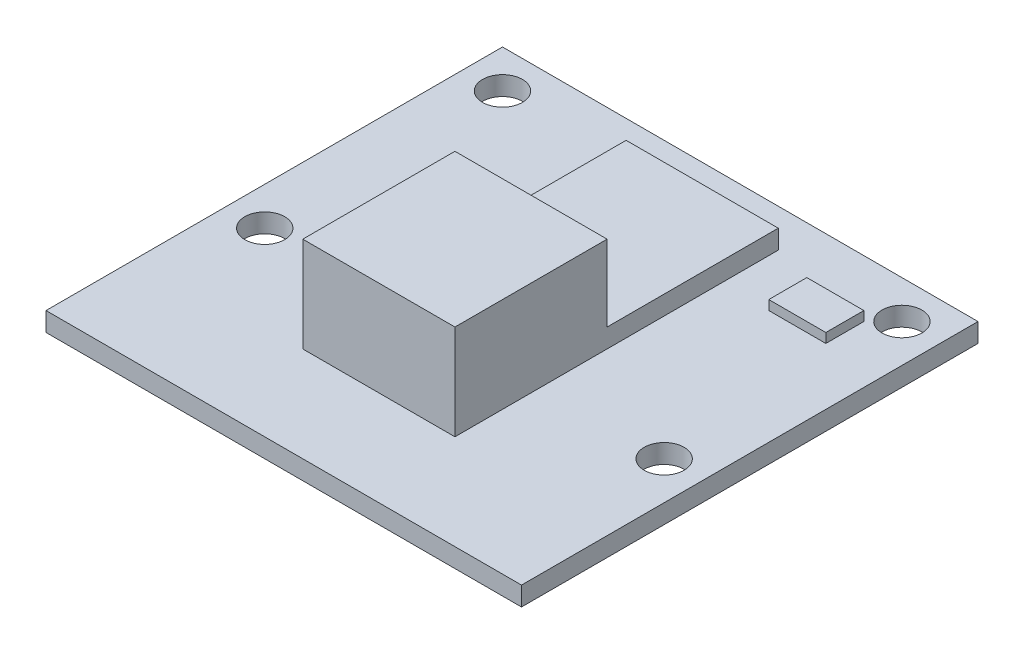
from build123d import *

# Parameters (mm, degrees)
SKETCH1_W           = 25
SKETCH1_H           = 24
BOSS_EXTRUDE1_DEPTH = 1
SKETCH2_W           = 8
SKETCH2_H           = 8
BOSS_EXTRUDE2_DEPTH = 5
SKETCH3_W           = 8
SKETCH3_H           = 9
BOSS_EXTRUDE3_DEPTH = 1
SKETCH4_W           = 3
SKETCH4_H           = 2
BOSS_EXTRUDE4_DEPTH = 0.5
CUT_EXTRUDE1_REACH  = 3
SKETCH5_R           = 1.048419625


with BuildPart() as part:
    # Sketch1 → Boss-Extrude1 (new body)
    with BuildSketch(Plane(origin=(0, 0, 0), x_dir=(1, 0, 0), z_dir=(0, 1, 0))):
        Rectangle(SKETCH1_W, SKETCH1_H)
    extrude(amount=BOSS_EXTRUDE1_DEPTH)

    # Sketch2 → Boss-Extrude2 (add)
    with BuildSketch(Plane(origin=(0, 1, 0), x_dir=(1, 0, 0), z_dir=(0, 1, 0))):
        with Locations((0, -3)):
            Rectangle(SKETCH2_W, SKETCH2_H)
    extrude(amount=BOSS_EXTRUDE2_DEPTH)

    # Sketch3 → Boss-Extrude3 (add)
    with BuildSketch(Plane(origin=(0, 1, 0), x_dir=(1, 0, 0), z_dir=(0, 1, 0))):
        with Locations((0, 5.5)):
            Rectangle(SKETCH3_W, SKETCH3_H)
    extrude(amount=BOSS_EXTRUDE3_DEPTH)

    # Sketch4 → Boss-Extrude4 (add)
    with BuildSketch(Plane(origin=(0, 1, 0), x_dir=(1, 0, 0), z_dir=(0, 1, 0))):
        with Locations((8, 8)):
            Rectangle(SKETCH4_W, SKETCH4_H)
    extrude(amount=BOSS_EXTRUDE4_DEPTH)

    # Sketch5 → Cut-Extrude1 (cut, up to next)
    with BuildSketch(Plane(origin=(0, 1, 0), x_dir=(1, 0, 0), z_dir=(0, 1, 0)), mode=Mode.PRIVATE) as cut_extrude1_sk1:
        with Locations((-10.5, 10)):
            Circle(SKETCH5_R)
    cut_extrude1_tool1 = extrude(cut_extrude1_sk1.sketch, amount=-CUT_EXTRUDE1_REACH, mode=Mode.PRIVATE) & part.part
    add(cut_extrude1_tool1.solids().sort_by_distance((-10.5, 1, -10))[0], mode=Mode.SUBTRACT)
    # Sketch5 → Cut-Extrude1 (cut, up to next)
    with BuildSketch(Plane(origin=(0, 1, 0), x_dir=(1, 0, 0), z_dir=(0, 1, 0)), mode=Mode.PRIVATE) as cut_extrude1_sk2:
        with Locations((10.5, 10)):
            Circle(SKETCH5_R)
    cut_extrude1_tool2 = extrude(cut_extrude1_sk2.sketch, amount=-CUT_EXTRUDE1_REACH, mode=Mode.PRIVATE) & part.part
    add(cut_extrude1_tool2.solids().sort_by_distance((10.5, 1, -10))[0], mode=Mode.SUBTRACT)
    # Sketch5 → Cut-Extrude1 (cut, up to next)
    with BuildSketch(Plane(origin=(0, 1, 0), x_dir=(1, 0, 0), z_dir=(0, 1, 0)), mode=Mode.PRIVATE) as cut_extrude1_sk3:
        with Locations((10.5, -2.5)):
            Circle(SKETCH5_R)
    cut_extrude1_tool3 = extrude(cut_extrude1_sk3.sketch, amount=-CUT_EXTRUDE1_REACH, mode=Mode.PRIVATE) & part.part
    add(cut_extrude1_tool3.solids().sort_by_distance((10.5, 1, 2.5))[0], mode=Mode.SUBTRACT)
    # Sketch5 → Cut-Extrude1 (cut, up to next)
    with BuildSketch(Plane(origin=(0, 1, 0), x_dir=(1, 0, 0), z_dir=(0, 1, 0)), mode=Mode.PRIVATE) as cut_extrude1_sk4:
        with Locations((-10.5, -2.5)):
            Circle(SKETCH5_R)
    cut_extrude1_tool4 = extrude(cut_extrude1_sk4.sketch, amount=-CUT_EXTRUDE1_REACH, mode=Mode.PRIVATE) & part.part
    add(cut_extrude1_tool4.solids().sort_by_distance((-10.5, 1, 2.5))[0], mode=Mode.SUBTRACT)


solid = part.part
